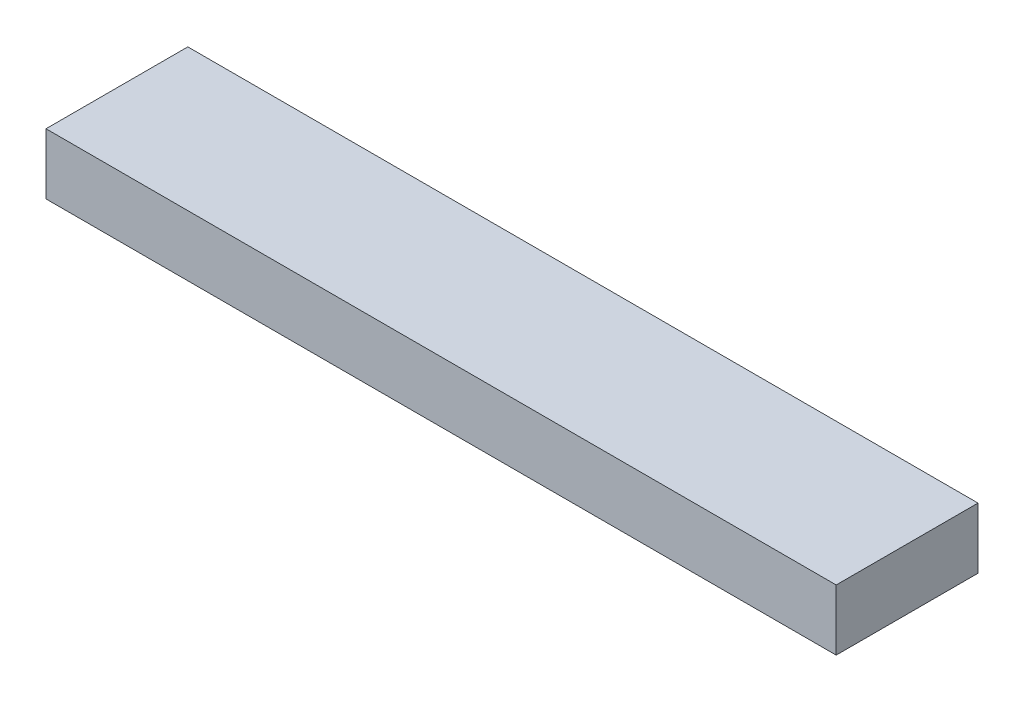
from build123d import *

# Parameters (mm, degrees)
SKETCH1_W           = 495.3
SKETCH1_H           = 88.9
BOSS_EXTRUDE1_DEPTH = 38.1


with BuildPart() as part:
    # Sketch1 → Boss-Extrude1 (new body)
    with BuildSketch(Plane(origin=(0, 0, 0), x_dir=(1, 0, 0), z_dir=(0, 1, 0))):
        with Locations((247.65, 44.45)):
            Rectangle(SKETCH1_W, SKETCH1_H)
    extrude(amount=BOSS_EXTRUDE1_DEPTH)


solid = part.part
